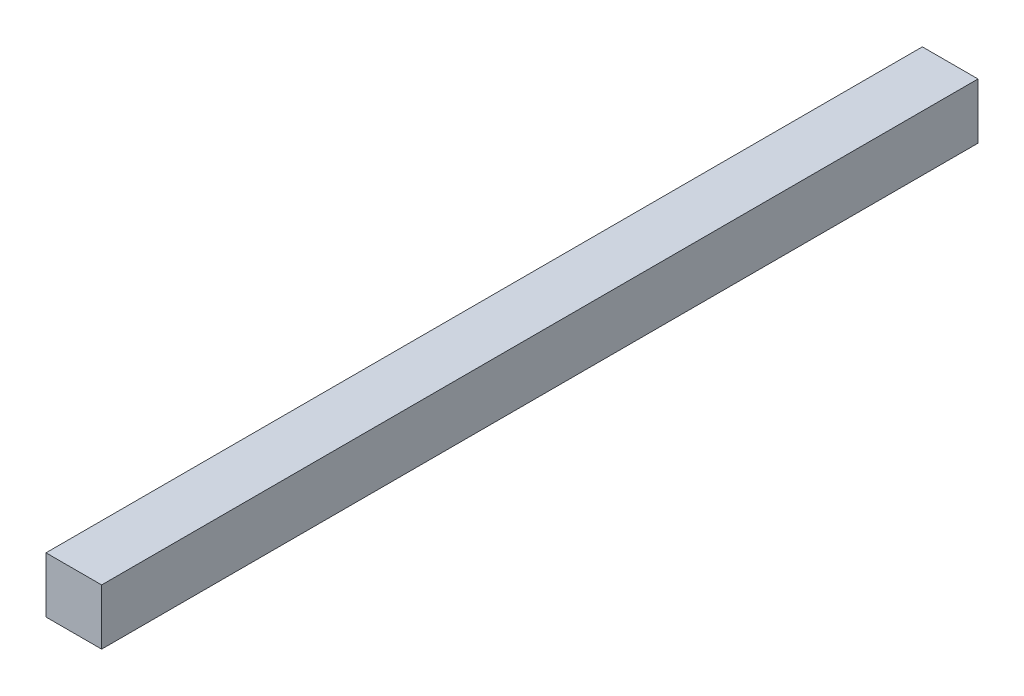
from build123d import *

# Parameters (mm, degrees)
SZKIC1_W                    = 20
SZKIC1_H                    = 20
DODANIE_WYCI_GNI_CIE1_DEPTH = 315


with BuildPart() as part:
    # Szkic1 → Dodanie-wyciągnięcie1 (new body)
    with BuildSketch(Plane.XY):
        with Locations((10, 10)):
            Rectangle(SZKIC1_W, SZKIC1_H)
    extrude(amount=-DODANIE_WYCI_GNI_CIE1_DEPTH)


solid = part.part
